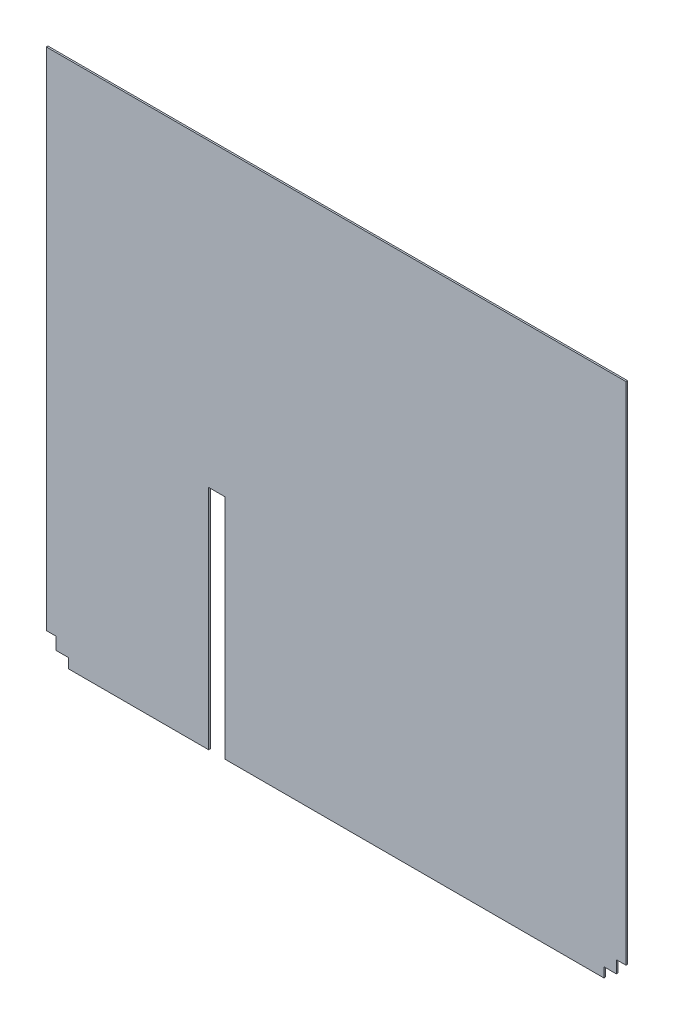
from build123d import *

# Parameters (mm, degrees)
BOSS_EXTRUDE1_DEPTH = 2.54


with BuildPart() as part:
    # Sketch1 → Boss-Extrude1 (new body)
    with BuildSketch(Plane.XY):
        Polygon((0, 825.5), (0, 34.544), (15.24, 34.544), (15.24, 15.24), (34.544, 15.24), (34.544, 0), (254, 0), (254, 355.6), (279.4, 355.6), (279.4, 0), (872.45698, 0), (872.45698, 15.24), (891.76098, 15.24), (891.76098, 34.544), (907.00098, 34.544), (907.00098, 825.5), align=None)
    extrude(amount=BOSS_EXTRUDE1_DEPTH)


solid = part.part
